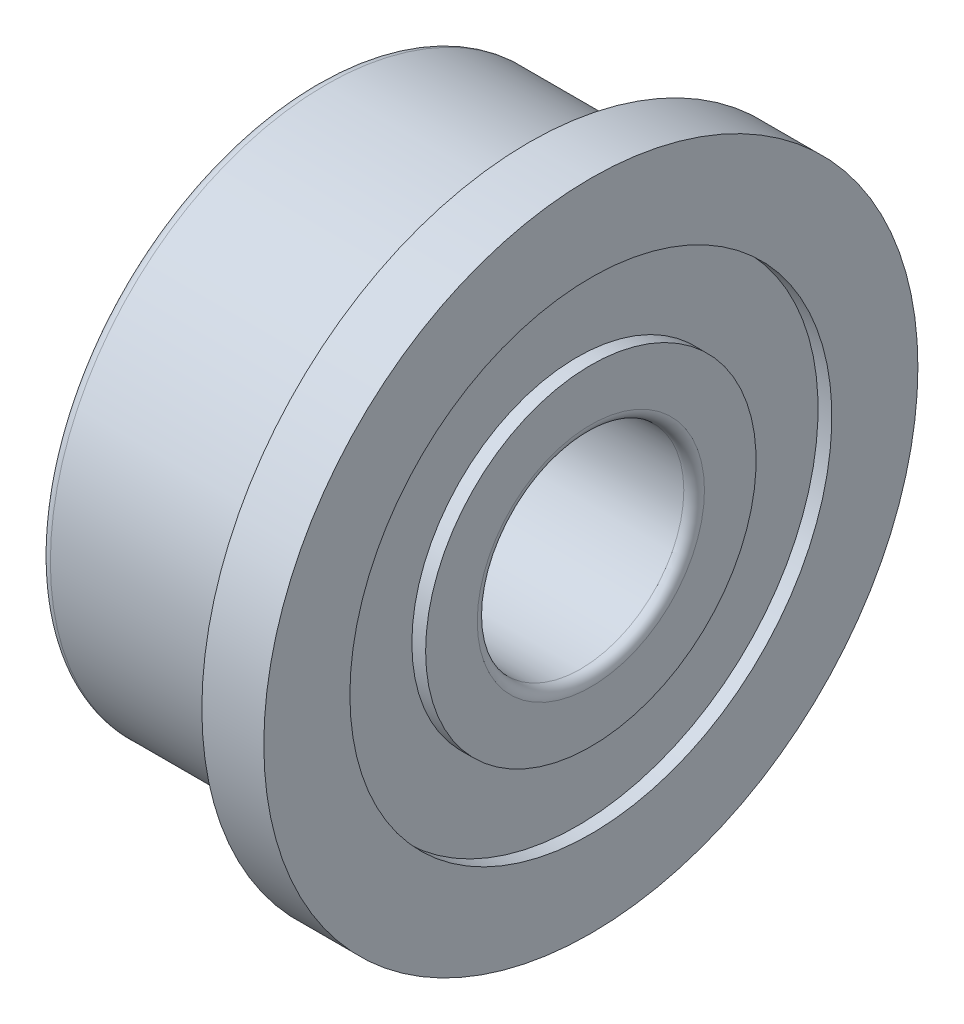
from build123d import *

# Parameters (mm, degrees)
FILLET1_R = 0.15


with BuildPart() as part:
    # Sketch1 → Revolve1 (revolve)
    with BuildSketch(Plane.XY):
        with BuildLine():
            Line((0, 4.2), (0, 4.75))
            Line((0, 4.75), (0.9, 4.75))
            Line((0.9, 4.75), (0.9, 3.5))
            Line((0.9, 3.5), (0.7, 3.5))
            Line((0.7, 3.5), (0.7, 2.4))
            Line((0.7, 2.4), (0.9, 2.4))
            Line((0.9, 2.4), (0.9, 1.5))
            Line((0.9, 1.5), (-3.1, 1.5))
            Line((-3.1, 1.5), (-3.1, 2.4))
            Line((-3.1, 2.4), (-2.9, 2.4))
            Line((-2.9, 2.4), (-2.9, 3.5))
            Line((-2.9, 3.5), (-3.1, 3.5))
            Line((-3.1, 3.5), (-3.1, 4))
            Line((-3.1, 4), (-0.2, 4))
            ThreePointArc((-0.2, 4), (0.141421356, 3.858578644), (0, 4.2))
        make_face()
    revolve(axis=Axis((-3.1, 0, 0), (1, 0, 0)))

    # Fillet1
    fillet1_edges = [part.edges().sort_by_distance(p)[0] for p in [
        (0.9, -1.5, 0),
        (-3.1, -1.5, 0),
        (-3.1, -4, 0),
    ]]
    fillet(fillet1_edges, radius=FILLET1_R)


solid = part.part
